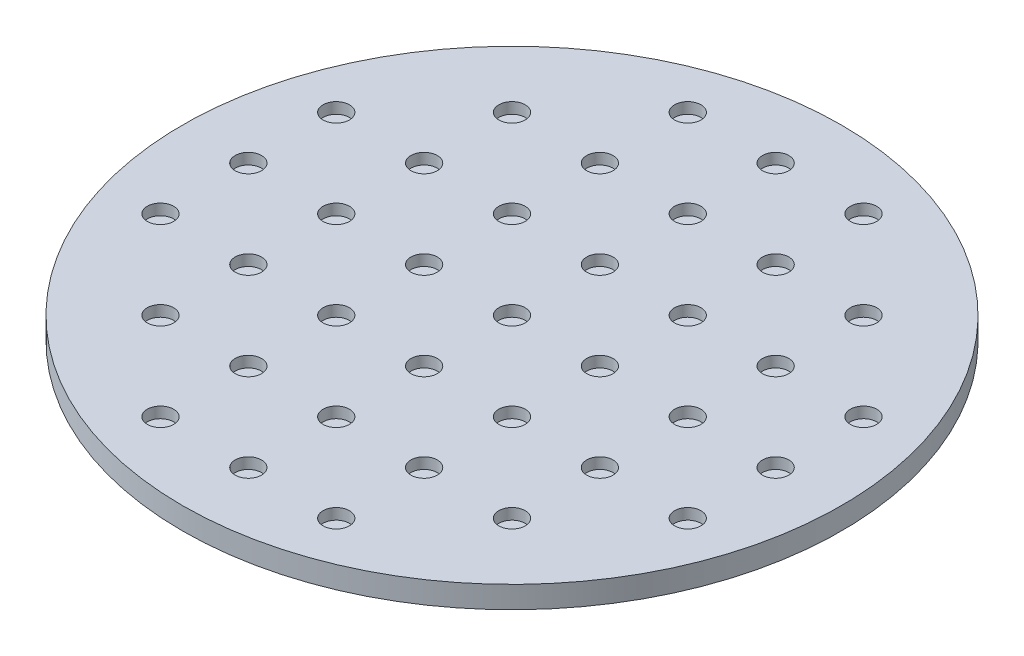
from build123d import *

# Parameters (mm, degrees)
SKETCH1_R           = 381
BOSS_EXTRUDE1_DEPTH = 12.7
SKETCH6_R           = 15.25
CUT_EXTRUDE1_DEPTH  = 12.7


with BuildPart() as part:
    # Sketch1 → Boss-Extrude1 (new body, symmetric)
    with BuildSketch(Plane(origin=(0, 0, 0), x_dir=(1, 0, 0), z_dir=(0, 1, 0))):
        Circle(SKETCH1_R)
    extrude(amount=BOSS_EXTRUDE1_DEPTH, both=True)

    # Sketch6 → Cut-Extrude1 (cut)
    with BuildSketch(Plane(origin=(0, 12.7, 0), x_dir=(1, 0, 0), z_dir=(0, 1, 0))):
        Circle(SKETCH6_R)
        with Locations((-101.6, 0)):
            Circle(SKETCH6_R)
        with Locations((101.6, 0)):
            Circle(SKETCH6_R)
        with Locations((-101.6, 101.6)):
            Circle(SKETCH6_R)
        with Locations((0, 101.6)):
            Circle(SKETCH6_R)
        with Locations((101.6, 101.6)):
            Circle(SKETCH6_R)
        with Locations((-101.6, -101.6)):
            Circle(SKETCH6_R)
        with Locations((0, -101.6)):
            Circle(SKETCH6_R)
        with Locations((101.6, -101.6)):
            Circle(SKETCH6_R)
        with Locations((101.6, 203.2)):
            Circle(SKETCH6_R)
        with Locations((0, 203.2)):
            Circle(SKETCH6_R)
        with Locations((-101.6, 203.2)):
            Circle(SKETCH6_R)
        with Locations((101.6, 304.8)):
            Circle(SKETCH6_R)
        with Locations((0, 304.8)):
            Circle(SKETCH6_R)
        with Locations((-101.6, 304.8)):
            Circle(SKETCH6_R)
        with Locations((101.6, -203.2)):
            Circle(SKETCH6_R)
        with Locations((0, -203.2)):
            Circle(SKETCH6_R)
        with Locations((-101.6, -203.2)):
            Circle(SKETCH6_R)
        with Locations((101.6, -304.8)):
            Circle(SKETCH6_R)
        with Locations((0, -304.8)):
            Circle(SKETCH6_R)
        with Locations((-101.6, -304.8)):
            Circle(SKETCH6_R)
        with Locations((203.2, -101.6)):
            Circle(SKETCH6_R)
        with Locations((203.2, 0)):
            Circle(SKETCH6_R)
        with Locations((203.2, 101.6)):
            Circle(SKETCH6_R)
        with Locations((304.8, -101.6)):
            Circle(SKETCH6_R)
        with Locations((304.8, 0)):
            Circle(SKETCH6_R)
        with Locations((304.8, 101.6)):
            Circle(SKETCH6_R)
        with Locations((-203.2, 101.6)):
            Circle(SKETCH6_R)
        with Locations((-203.2, 0)):
            Circle(SKETCH6_R)
        with Locations((-203.2, -101.6)):
            Circle(SKETCH6_R)
        with Locations((-304.8, 101.6)):
            Circle(SKETCH6_R)
        with Locations((-304.8, 0)):
            Circle(SKETCH6_R)
        with Locations((-304.8, -101.6)):
            Circle(SKETCH6_R)
        with Locations((-203.2, 203.2)):
            Circle(SKETCH6_R)
        with Locations((203.2, 203.2)):
            Circle(SKETCH6_R)
        with Locations((203.2, -203.2)):
            Circle(SKETCH6_R)
        with Locations((-203.2, -203.2)):
            Circle(SKETCH6_R)
    extrude(amount=-CUT_EXTRUDE1_DEPTH, mode=Mode.SUBTRACT)


solid = part.part
